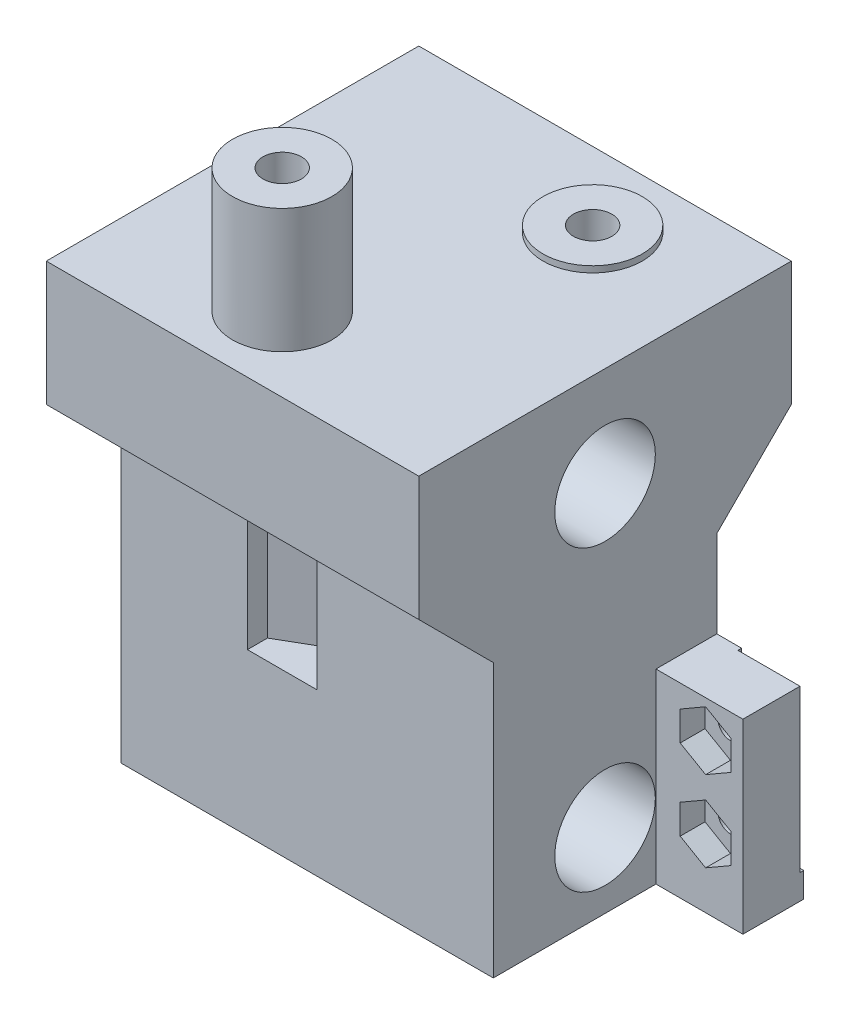
from build123d import *

# Parameters (mm, degrees)
SKETCH_1_W          = 30
SKETCH_1_H          = 30
EXTRUDE_1_DEPTH     = 38
SKETCH_3_R          = 4
EXTRUDE_3_DEPTH     = 0.5
SKETCH_7_R          = 4
EXTRUDE_4_DEPTH     = 10
SKETCH_6_R          = 4.05
CUT_EXTRUDE_3_DEPTH = 31
SKETCH_9_R          = 1.55
CUT_EXTRUDE_4_DEPTH = 21
CUT_EXTRUDE_6_DEPTH = 31
CUT_EXTRUDE_5_DEPTH = 15
SKETCH_12_W         = 4.9
SKETCH_12_H         = 15
EXTRUDE_5_DEPTH     = 7
SKETCH_13_W         = 5
SKETCH_13_H         = 13
CUT_EXTRUDE_7_DEPTH = 0.3
SKETCH_14_R         = 1
CUT_EXTRUDE_8_DEPTH = 24.7
CUT_EXTRUDE_9_DEPTH = 2


with BuildPart() as part:
    # 草图1 → 凸台-拉伸1 (new body)
    with BuildSketch(Plane(origin=(0, 0, 0), x_dir=(1, 0, 0), z_dir=(0, 1, 0))):
        with Locations((15, 15)):
            Rectangle(SKETCH_1_W, SKETCH_1_H)
    extrude(amount=EXTRUDE_1_DEPTH)

    # 草图3 → 凸台-拉伸3 (add)
    with BuildSketch(Plane(origin=(0, 38, -50), x_dir=(1, 0, 0), z_dir=(0, -1, 0))):
        with Locations((20, 26)):
            Circle(SKETCH_3_R)
    extrude(amount=-EXTRUDE_3_DEPTH)

    # 草图7 → 凸台-拉伸4 (add)
    with BuildSketch(Plane.XZ.offset(-38)):
        with Locations((13, -6)):
            Circle(SKETCH_7_R)
    extrude(amount=-EXTRUDE_4_DEPTH)

    # 草图6 → 切除-拉伸3 (cut, through all)
    with BuildSketch(Plane(origin=(30, 0, 0), x_dir=(0, 0, -1), z_dir=(1, 0, 0))):
        with Locations((15, 6)):
            Circle(SKETCH_6_R)
        with Locations((15, 30)):
            Circle(SKETCH_6_R)
    extrude(amount=-CUT_EXTRUDE_3_DEPTH, mode=Mode.SUBTRACT)

    # 草图9 → 切除-拉伸4 (cut, through all)
    with BuildSketch(Plane(origin=(0, 28, 0), x_dir=(1, 0, 0), z_dir=(0, 1, 0))):
        with Locations((13, 6)):
            Circle(SKETCH_9_R)
        with Locations((20, 24)):
            Circle(SKETCH_9_R)
    extrude(amount=CUT_EXTRUDE_4_DEPTH, mode=Mode.SUBTRACT)

    # 草图11 → 切除-拉伸6 (cut, through all)
    with BuildSketch(Plane(origin=(30, 0, 0), x_dir=(0, 0, -1), z_dir=(1, 0, 0))):
        Polygon((6, 0), (6, 22), (0, 28), (0, 0), align=None)
        Polygon((24, 0), (24, 22), (30, 28), (30, 0), align=None)
    extrude(amount=-CUT_EXTRUDE_6_DEPTH, mode=Mode.SUBTRACT)

    # 草图10 → 切除-拉伸5 (cut)
    with BuildSketch(Plane(origin=(0, 28, 0), x_dir=(1, 0, 0), z_dir=(0, 1, 0))):
        Polygon((15.8, 0), (15.8, 7.616580754), (13, 9.233161507), (10.2, 7.616580754), (10.2, 0), align=None)
        Polygon((20, 20.766838493), (22.8, 22.383419246), (22.8, 30), (17.2, 30), (17.2, 22.383419246), align=None)
    extrude(amount=-CUT_EXTRUDE_5_DEPTH, mode=Mode.SUBTRACT)

    # 草图12 → 凸台-拉伸5 (add)
    with BuildSketch(Plane(origin=(30, 0, 0), x_dir=(0, 0, -1), z_dir=(1, 0, 0))):
        with Locations((21.55, 7.5)):
            Rectangle(SKETCH_12_W, SKETCH_12_H)
    extrude(amount=EXTRUDE_5_DEPTH)

    # 草图13 → 切除-拉伸7 (cut)
    with BuildSketch(Plane(origin=(0, 0, -24), x_dir=(-1, 0, 0), z_dir=(0, 0, -1))):
        with Locations((-34.5, 8.5)):
            Rectangle(SKETCH_13_W, SKETCH_13_H)
    extrude(amount=-CUT_EXTRUDE_7_DEPTH, mode=Mode.SUBTRACT)

    # 草图14 → 切除-拉伸8 (cut, through all)
    with BuildSketch(Plane(origin=(0, 0, -23.7), x_dir=(-1, 0, 0), z_dir=(0, 0, -1))):
        with Locations((-34, 12)):
            Circle(SKETCH_14_R)
        with Locations((-34, 5.5)):
            Circle(SKETCH_14_R)
    extrude(amount=-CUT_EXTRUDE_8_DEPTH, mode=Mode.SUBTRACT)

    # 草图15 → 切除-拉伸9 (cut)
    with BuildSketch(Plane.XY.offset(-19.1)):
        Polygon((36.05, 10.816431948), (36.05, 13.183568052), (34, 14.367136104), (31.95, 13.183568052), (31.95, 10.816431948), (34, 9.632863896), align=None)
        Polygon((34, 3.132863896), (36.05, 4.316431948), (36.05, 6.683568052), (34, 7.867136104), (31.95, 6.683568052), (31.95, 4.316431948), align=None)
    extrude(amount=-CUT_EXTRUDE_9_DEPTH, mode=Mode.SUBTRACT)


solid = part.part
